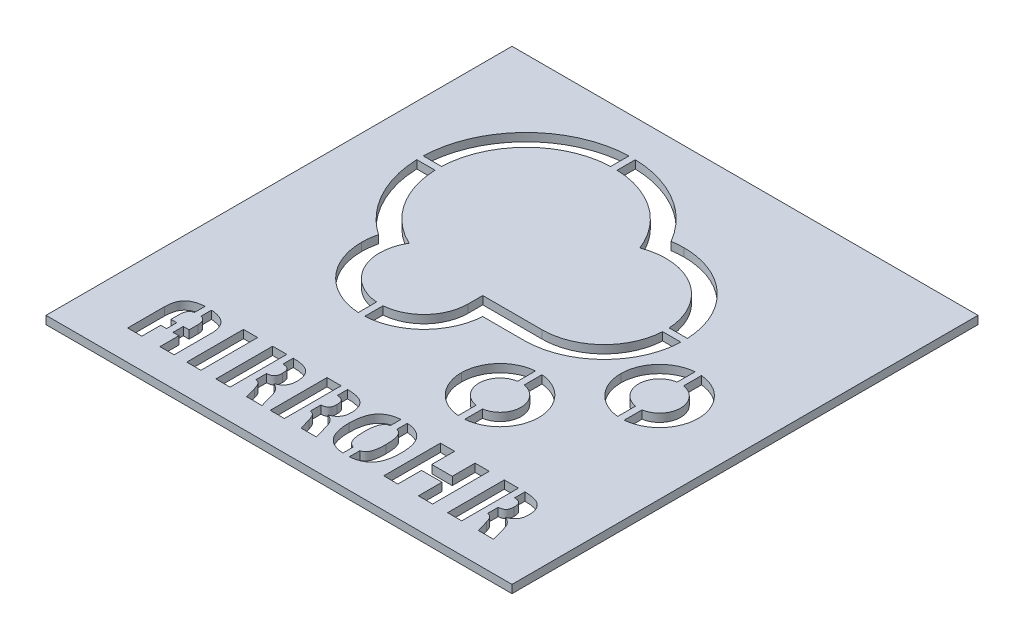
from build123d import *

# Parameters (mm, degrees)
BOSS_EXTRUDE2_DEPTH   = 2
SKETCH4_W             = 115
SKETCH4_H             = 115
BOSS_EXTRUDE2_2_DEPTH = 2
BOSS_EXTRUDE2_3_DEPTH = 2
BOSS_EXTRUDE2_4_DEPTH = 2
SKETCH5_W             = 3.5
SKETCH5_H             = 14
CUT_EXTRUDE1_DEPTH    = 2
SKETCH6_W             = 1.6
SKETCH6_H             = 9.016392518
SKETCH6_W_2           = 12.548523478
SKETCH6_H_2           = 1.6
SKETCH6_W_3           = 7.900848197
SKETCH6_H_3           = 10.834577131
SKETCH6_H_4           = 23.73823121
SKETCH6_H_5           = 23.744170643
BOSS_EXTRUDE3_DEPTH   = 2
SKETCH7_W             = 1.6
SKETCH7_H             = 20.194444444
BOSS_EXTRUDE4_DEPTH   = 2


with BuildPart() as part:
    # Sketch4 → Boss-Extrude2 (new body)
    with BuildSketch(Plane(origin=(0, 0, 0), x_dir=(1, 0, 0), z_dir=(0, 1, 0))):
        with BuildLine():
            Line((-7.842765972, -9.564784729), (-7.842765972, -13.155399048))
            add(Edge.make_bspline(
                [(-7.842765972, -13.155399048), (-7.842935541, -19.185382566), (-12.733091514, -24.0752597), (-18.763092198, -24.075090131)],
                knots=[6, 6, 6, 6, 7, 7, 7, 7], degree=3))
            add(Edge.make_bspline(
                [(-18.763092198, -24.075090131), (-24.793092882, -24.074920559), (-29.682935683, -19.1847684), (-29.682766111, -13.154784881)],
                knots=[7, 7, 7, 7, 8, 8, 8, 8], degree=3))
            add(Edge.make_bspline(
                [(-29.682766111, -13.154784881), (-29.682766111, -11.079765045), (-29.102785261, -9.139766418), (-28.09776512, -7.489764892)],
                knots=[8, 8, 8, 8, 9, 9, 9, 9], degree=3))
            add(Edge.make_bspline(
                [(-28.09776512, -7.489764892), (-35.447785528, -4.019767486), (-40.527766378, 3.460212982), (-40.527766378, 12.125213898)],
                knots=[9, 9, 9, 9, 10, 10, 10, 10], degree=3))
            add(Edge.make_bspline(
                [(-40.527766378, 12.125213898), (-40.527766378, 24.100233353), (-30.81776634, 33.810213364), (-18.837766798, 33.810213364)],
                knots=[10, 10, 10, 10, 11, 11, 11, 11], degree=3))
            add(Edge.make_bspline(
                [(-18.837766798, 33.810213364), (-9.632766874, 33.810213364), (-1.767746122, 28.070232666), (1.377235262, 19.980232514)],
                knots=[0, 0, 0, 0, 1, 1, 1, 1], degree=3))
            add(Edge.make_bspline(
                [(1.377235262, 19.980232514), (3.067233889, 20.625213898), (4.902232973, 20.980232514), (6.822234957, 20.980232514)],
                knots=[1, 1, 1, 1, 2, 2, 2, 2], degree=3))
            add(Edge.make_bspline(
                [(6.822234957, 20.980232514), (15.257232515, 20.980232514), (22.0922316, 14.145214356), (22.0922316, 5.710212982)],
                knots=[2, 2, 2, 2, 3, 3, 3, 3], degree=3))
            add(Edge.make_bspline(
                [(22.0922316, 5.710212982), (22.0922316, -2.724784576), (15.257232515, -9.564784729), (6.822234957, -9.564784729)],
                knots=[3, 3, 3, 3, 4, 4, 4, 4], degree=3))
            Line((6.822234957, -9.564784729), (-7.842765972, -9.564784729))
        make_face()
    extrude(amount=BOSS_EXTRUDE2_DEPTH)



with BuildPart() as body_2:
    # Sketch4 → Boss-Extrude2 2 (new body)
    with BuildSketch(Plane(origin=(0, 0, 0), x_dir=(1, 0, 0), z_dir=(0, 1, 0))):
        with Locations((0, -10.190399849)):
            Rectangle(SKETCH4_W, SKETCH4_H)
        with BuildLine():
            Line((-3.369278118, -14.064975464), (6.822040394, -14.06540271))
            add(Edge.make_bspline(
                [(6.822040394, -14.06540271), (17.723441914, -14.06540271), (26.592231587, -5.194381439), (26.592231587, 5.709598816)],
                knots=[6, 6, 6, 6, 7, 7, 7, 7], degree=3))
            add(Edge.make_bspline(
                [(26.592231587, 5.709598816), (26.592231587, 16.610832489), (17.723441914, 25.479618347), (6.822234944, 25.479618347)],
                knots=[7, 7, 7, 7, 8, 8, 8, 8], degree=3))
            add(Edge.make_bspline(
                [(6.822234944, 25.479618347), (5.811405018, 25.479618347), (4.809924916, 25.403877533), (3.82228835, 25.253231323)],
                knots=[8, 8, 8, 8, 9, 9, 9, 9], degree=3))
            add(Edge.make_bspline(
                [(3.82228835, 25.253231323), (1.910270527, 28.555517471), (-0.706497356, 31.405149735), (-3.884784862, 33.620214737)],
                knots=[9, 9, 9, 9, 10, 10, 10, 10], degree=3))
            add(Edge.make_bspline(
                [(-3.884784862, 33.620214737), (-8.286651775, 36.688041962), (-13.457325145, 38.309600151), (-18.837766811, 38.309600151)],
                knots=[10, 10, 10, 10, 11, 11, 11, 11], degree=3))
            add(Edge.make_bspline(
                [(-18.837766811, 38.309600151), (-33.278976604, 38.309600151), (-45.027765915, 26.563061035), (-45.027765915, 12.124599732)],
                knots=[0, 0, 0, 0, 1, 1, 1, 1], degree=3))
            add(Edge.make_bspline(
                [(-45.027765915, 12.124599732), (-45.027765915, 3.483356751), (-40.700526401, -4.580489838), (-33.724340602, -9.419315063)],
                knots=[1, 1, 1, 1, 2, 2, 2, 2], degree=3))
            add(Edge.make_bspline(
                [(-33.724340602, -9.419315063), (-34.027487918, -10.634566986), (-34.182766124, -11.888732635), (-34.182766124, -13.155399048)],
                knots=[2, 2, 2, 2, 3, 3, 3, 3], degree=3))
            add(Edge.make_bspline(
                [(-34.182766124, -13.155399048), (-34.182766124, -21.65801593), (-27.265400096, -28.575397217), (-18.762785122, -28.575397217)],
                knots=[3, 3, 3, 3, 4, 4, 4, 4], degree=3))
            add(Edge.make_bspline(
                [(-18.762785122, -28.575397217), (-10.565300151, -28.575397217), (-3.841350719, -22.146121704), (-3.369278118, -14.064975464)],
                knots=[4, 4, 4, 4, 5, 5, 5, 5], degree=3))
        make_face(mode=Mode.SUBTRACT)
        with BuildLine():
            add(Edge.make_bspline(
                [(15.583556965, -38.288196289), (20.8599623, -38.288196289), (25.152625874, -33.995532715), (25.152625874, -28.71912738)],
                knots=[2, 2, 2, 2, 3, 3, 3, 3], degree=3))
            add(Edge.make_bspline(
                [(25.152625874, -28.71912738), (25.152625874, -23.442722046), (20.8599623, -19.150058472), (15.583556965, -19.150058472)],
                knots=[3, 3, 3, 3, 4, 4, 4, 4], degree=3))
            add(Edge.make_bspline(
                [(15.583556965, -19.150058472), (10.307151631, -19.150058472), (6.014484242, -23.442722046), (6.014484242, -28.71912738)],
                knots=[0, 0, 0, 0, 1, 1, 1, 1], degree=3))
            add(Edge.make_bspline(
                [(6.014484242, -28.71912738), (6.014484242, -33.995532715), (10.307151631, -38.288196289), (15.583556965, -38.288196289)],
                knots=[1, 1, 1, 1, 2, 2, 2, 2], degree=3))
        make_face(mode=Mode.SUBTRACT)
        with BuildLine():
            add(Edge.make_bspline(
                [(25.878173664, -9.214587891), (25.878173664, -14.490993225), (30.170837239, -18.783656799), (35.447242573, -18.783656799)],
                knots=[1, 1, 1, 1, 2, 2, 2, 2], degree=3))
            add(Edge.make_bspline(
                [(35.447242573, -18.783656799), (40.723647908, -18.783656799), (45.016311482, -14.490993225), (45.016311482, -9.214587891)],
                knots=[2, 2, 2, 2, 3, 3, 3, 3], degree=3))
            add(Edge.make_bspline(
                [(45.016311482, -9.214587891), (45.016311482, -3.938182556), (40.723647908, 0.354484833), (35.447242573, 0.354484833)],
                knots=[3, 3, 3, 3, 4, 4, 4, 4], degree=3))
            add(Edge.make_bspline(
                [(35.447242573, 0.354484833), (30.170837239, 0.354484833), (25.878173664, -3.938182556), (25.878173664, -9.214587891)],
                knots=[0, 0, 0, 0, 1, 1, 1, 1], degree=3))
        make_face(mode=Mode.SUBTRACT)
    extrude(amount=BOSS_EXTRUDE2_2_DEPTH)

    # Sketch5 → Cut-Extrude1 (cut)
    with BuildSketch(Plane(origin=(0, 2, 0), x_dir=(1, 0, 0), z_dir=(0, 1, 0))):
        with BuildLine():
            Line((-41.222222222, -60.324270548), (-44.722222222, -60.324270548))
            Line((-44.722222222, -60.324270548), (-44.722222222, -51.267412909))
            add(Edge.make_bspline(
                [(-44.722222222, -51.267412909), (-44.718630096, -51.075892532), (-44.711603403, -50.70125237), (-44.659502845, -50.154032457), (-44.573962658, -49.634407069), (-44.459047775, -49.141700933), (-44.298206685, -48.678929554), (-44.089121514, -48.250981461), (-43.826820441, -47.861085276), (-43.518137808, -47.505226321), (-43.156485853, -47.187487984), (-42.741812509, -46.909169818), (-42.272971127, -46.672327608), (-41.748321644, -46.474965295), (-41.162877239, -46.315865875), (-40.510620907, -46.20709583), (-39.791637792, -46.13992868), (-39.29009159, -46.133287839), (-39.028645833, -46.129826104)],
                knots=[0, 0, 0, 0, 0.000574508, 0.001123817, 0.001647269, 0.002153518, 0.002639724, 0.003113926, 0.003578223, 0.004045522, 0.004523399, 0.005018037, 0.005539802, 0.006095601, 0.006697017, 0.007356837, 0.00807696, 0.008861103, 0.008861103, 0.008861103, 0.008861103], degree=3))
            add(Edge.make_bspline(
                [(-39.028645833, -46.129826104), (-38.766193514, -46.133319316), (-38.262637675, -46.140021589), (-37.541549788, -46.206713305), (-36.886521498, -46.316690693), (-36.296927983, -46.474962778), (-35.766199268, -46.67231066), (-35.291531054, -46.909322701), (-34.870759525, -47.186368182), (-34.505957291, -47.506173563), (-34.190881765, -47.860627047), (-33.923166042, -48.251434416), (-33.704355092, -48.678309085), (-33.534343881, -49.141237367), (-33.410700461, -49.63410981), (-33.314159013, -50.153291305), (-33.260253638, -50.701161959), (-33.253467993, -51.075895101), (-33.25, -51.267412909)],
                knots=[0, 0, 0, 0, 0.00078718, 0.001510327, 0.002170147, 0.002777429, 0.003338912, 0.003866098, 0.004365786, 0.004845946, 0.005317258, 0.005784962, 0.006263263, 0.006752563, 0.007261023, 0.007786033, 0.008335636, 0.008910144, 0.008910144, 0.008910144, 0.008910144], degree=3))
            Line((-33.25, -51.267412909), (-33.25, -60.324270548))
            Line((-33.25, -60.324270548), (-36.75, -60.324270548))
            Line((-36.75, -60.324270548), (-36.75, -55.657603882))
            Line((-36.75, -55.657603882), (-41.222222222, -55.657603882))
            Line((-41.222222222, -55.657603882), (-41.222222222, -60.324270548))
        make_face()
        with BuildLine():
            Line((-36.75, -53.129826104), (-36.75, -50.975746243))
            add(Edge.make_bspline(
                [(-36.75, -50.975746243), (-36.751933258, -50.883543096), (-36.755679301, -50.704882493), (-36.779325002, -50.444710356), (-36.822248778, -50.202188177), (-36.878587301, -49.97579093), (-36.955280652, -49.767138409), (-37.049224073, -49.575813978), (-37.158991279, -49.401490084), (-37.284103764, -49.244142011), (-37.429713006, -49.106030456), (-37.593404479, -48.982661933), (-37.781122939, -48.885389065), (-37.982680392, -48.79690934), (-38.206943614, -48.735026033), (-38.449885716, -48.690036828), (-38.712045217, -48.662421305), (-38.892872016, -48.659242802), (-38.986111111, -48.657603882)],
                knots=[0, 0, 0, 0, 0.000276626, 0.000536014, 0.000782763, 0.001014882, 0.001234999, 0.001448323, 0.001653147, 0.001851958, 0.002049651, 0.002253821, 0.002464532, 0.002682352, 0.002913135, 0.003160426, 0.003423138, 0.0037028, 0.0037028, 0.0037028, 0.0037028], degree=3))
            add(Edge.make_bspline(
                [(-38.986111111, -48.657603882), (-39.079350206, -48.659242802), (-39.260177005, -48.662421305), (-39.522336506, -48.690036828), (-39.765278608, -48.735026033), (-39.989541831, -48.79690934), (-40.191099283, -48.885389065), (-40.378817743, -48.982661933), (-40.542509216, -49.106030456), (-40.688118458, -49.244142011), (-40.813230943, -49.401490084), (-40.92299815, -49.575813978), (-41.01694157, -49.767138409), (-41.093634921, -49.97579093), (-41.149973444, -50.202188177), (-41.192897221, -50.444710356), (-41.216542921, -50.704882493), (-41.220288965, -50.883543096), (-41.222222222, -50.975746243)],
                knots=[0, 0, 0, 0, 0.000279662, 0.000542374, 0.000789665, 0.001020448, 0.001238268, 0.001448979, 0.001653149, 0.001850842, 0.002049653, 0.002254477, 0.002467801, 0.002687918, 0.002920037, 0.003166786, 0.003426174, 0.0037028, 0.0037028, 0.0037028, 0.0037028], degree=3))
            Line((-41.222222222, -50.975746243), (-41.222222222, -53.129826104))
            Line((-41.222222222, -53.129826104), (-36.75, -53.129826104))
        make_face(mode=Mode.SUBTRACT)
        with Locations((-28.388888889, -53.324270548)):
            Rectangle(SKETCH5_W, SKETCH5_H)
        with BuildLine():
            add(Edge.make_bspline(
                [(-18.144097222, -46.324270548), (-17.914161938, -46.327621932), (-17.468123346, -46.334123094), (-16.821971374, -46.371585948), (-16.220556147, -46.441684265), (-15.663311684, -46.538131651), (-15.146381878, -46.660942423), (-14.677005595, -46.833108754), (-14.249236029, -47.03798271), (-13.869484241, -47.290174742), (-13.531179835, -47.58081433), (-13.237571737, -47.913339551), (-12.991575073, -48.290574728), (-12.791807589, -48.710011632), (-12.631260833, -49.175207977), (-12.52233888, -49.690434341), (-12.454537253, -50.255901969), (-12.447898826, -50.649437677), (-12.444444444, -50.854218465)],
                knots=[0, 0, 0, 0, 0.000689837, 0.001338177, 0.001940767, 0.002505193, 0.003034266, 0.003532122, 0.004002258, 0.004453918, 0.004895502, 0.005336794, 0.005780037, 0.006242053, 0.006727261, 0.007252878, 0.007818904, 0.008432988, 0.008432988, 0.008432988, 0.008432988], degree=3))
            add(Edge.make_bspline(
                [(-12.444444444, -50.854218465), (-12.44632048, -50.981943127), (-12.449948385, -51.228939036), (-12.490399929, -51.583468023), (-12.552472309, -51.909536672), (-12.644193796, -52.205271029), (-12.758521575, -52.474215962), (-12.886308552, -52.722809597), (-13.030924162, -52.950378557), (-13.244964039, -53.21868066), (-13.540644328, -53.511428788), (-13.938660281, -53.787969721), (-14.351819233, -54.008615948), (-14.633110412, -54.130234846), (-14.771701389, -54.190155965)],
                knots=[0, 0, 0, 0, 0.000383005, 0.000740662, 0.001068969, 0.001377447, 0.001667479, 0.001944689, 0.002215224, 0.002474772, 0.002973203, 0.003457068, 0.003923349, 0.004376203, 0.004376203, 0.004376203, 0.004376203], degree=3))
            add(Edge.make_bspline(
                [(-14.771701389, -54.190155965), (-14.642823998, -54.245218696), (-14.389914439, -54.353274042), (-14.037611931, -54.558592868), (-13.721590982, -54.797263388), (-13.429375266, -55.065997046), (-13.169755896, -55.389150161), (-12.941169155, -55.77768305), (-12.744923213, -56.237063719), (-12.643621617, -56.57196297), (-12.590277778, -56.748315687)],
                knots=[0, 0, 0, 0, 0.000420162, 0.000824527, 0.001219492, 0.001606406, 0.002012571, 0.002458068, 0.002954745, 0.003507204, 0.003507204, 0.003507204, 0.003507204], degree=3))
            Line((-12.590277778, -56.748315687), (-11.560329861, -60.324270548))
            Line((-11.560329861, -60.324270548), (-15.327690972, -60.324270548))
            Line((-15.327690972, -60.324270548), (-16.138888889, -57.556475409))
            add(Edge.make_bspline(
                [(-16.138888889, -57.556475409), (-16.189175659, -57.389603296), (-16.284077937, -57.07467864), (-16.430208893, -56.702253486), (-16.554398353, -56.436443287), (-16.655075347, -56.260254093), (-16.774065288, -56.107392268), (-16.938385992, -55.923161051), (-17.18904089, -55.732089812), (-17.483907531, -55.60208951), (-17.747458575, -55.533140016), (-17.968061139, -55.48742775), (-18.210678935, -55.470133723), (-18.379051456, -55.465537127), (-18.466145833, -55.463159437)],
                knots=[0, 0, 0, 0, 0.000522711, 0.000986471, 0.001198471, 0.001402731, 0.001593534, 0.00177849, 0.00214249, 0.002528712, 0.002736556, 0.002959403, 0.003203387, 0.003464831, 0.003464831, 0.003464831, 0.003464831], degree=3))
            add(Edge.make_bspline(
                [(-18.466145833, -55.463159437), (-18.549189815, -55.463159437), (-18.720341435, -55.463159437), (-18.975549769, -55.463159437), (-19.218605324, -55.463159437), (-19.373553241, -55.463159437), (-19.444444444, -55.463159437)],
                knots=[0, 0, 0, 0, 0.000249132, 0.000513455, 0.000765625, 0.000978299, 0.000978299, 0.000978299, 0.000978299], degree=3))
            Line((-19.444444444, -55.463159437), (-19.444444444, -60.324270548))
            Line((-19.444444444, -60.324270548), (-22.944444444, -60.324270548))
            Line((-22.944444444, -60.324270548), (-22.944444444, -46.324270548))
            Line((-22.944444444, -46.324270548), (-18.144097222, -46.324270548))
        make_face()
        with BuildLine():
            add(Edge.make_bspline(
                [(-19.444444444, -52.874617771), (-19.341248676, -52.886864369), (-19.133266311, -52.911546355), (-18.821803568, -52.928215224), (-18.521861585, -52.932389432), (-18.327402149, -52.934419541), (-18.235243056, -52.935381659)],
                knots=[0, 0, 0, 0, 0.000311693, 0.00062819, 0.000935108, 0.0012116, 0.0012116, 0.0012116, 0.0012116], degree=3))
            add(Edge.make_bspline(
                [(-18.235243056, -52.935381659), (-18.137933608, -52.934988452), (-17.949056726, -52.934225239), (-17.677758503, -52.906485456), (-17.425084051, -52.876889917), (-17.196144051, -52.82379088), (-16.98525581, -52.761781288), (-16.799392867, -52.678886989), (-16.630135867, -52.587895833), (-16.48283296, -52.47719635), (-16.354229165, -52.348233086), (-16.241527622, -52.200050725), (-16.153859223, -52.02738246), (-16.070691118, -51.838541476), (-16.017231926, -51.624615592), (-15.973064329, -51.392541002), (-15.950155849, -51.139240773), (-15.946396406, -50.963628356), (-15.944444444, -50.872447632)],
                knots=[0, 0, 0, 0, 0.00029173, 0.000566246, 0.000817609, 0.001054218, 0.001270443, 0.001475897, 0.001663578, 0.00184587, 0.002026329, 0.002208621, 0.002401636, 0.002605897, 0.002826265, 0.003061053, 0.003314392, 0.003587981, 0.003587981, 0.003587981, 0.003587981], degree=3))
            add(Edge.make_bspline(
                [(-15.944444444, -50.872447632), (-15.946323512, -50.774167334), (-15.949913514, -50.58640064), (-15.973328703, -50.317099572), (-16.015141713, -50.075192306), (-16.072805036, -49.858031443), (-16.147913821, -49.665546049), (-16.242522434, -49.496474514), (-16.355634766, -49.350012307), (-16.492822509, -49.230770407), (-16.646275415, -49.130998432), (-16.814544676, -49.044321721), (-17.000677798, -48.978188291), (-17.281137183, -48.912613128), (-17.679601745, -48.86291617), (-18.011270644, -48.85584942), (-18.189670139, -48.852048326)],
                knots=[0, 0, 0, 0, 0.000294846, 0.000563309, 0.000810059, 0.001030427, 0.001236353, 0.001428169, 0.001609903, 0.001788537, 0.00197055, 0.002158059, 0.002355073, 0.002561402, 0.003021165, 0.00355631, 0.00355631, 0.00355631, 0.00355631], degree=3))
            Line((-18.189670139, -48.852048326), (-19.444444444, -48.852048326))
            Line((-19.444444444, -48.852048326), (-19.444444444, -52.874617771))
        make_face(mode=Mode.SUBTRACT)
        with BuildLine():
            add(Edge.make_bspline(
                [(-4.727430556, -46.324270548), (-4.497495271, -46.327621932), (-4.051456679, -46.334123094), (-3.405304708, -46.371585948), (-2.803889481, -46.441684265), (-2.246645017, -46.538131651), (-1.729715211, -46.660942423), (-1.260338929, -46.833108754), (-0.832569363, -47.03798271), (-0.452817574, -47.290174742), (-0.114513169, -47.58081433), (0.179094929, -47.913339551), (0.425091594, -48.290574728), (0.624859078, -48.710011632), (0.785405833, -49.175207977), (0.894327787, -49.690434341), (0.962129414, -50.255901969), (0.968767841, -50.649437677), (0.972222222, -50.854218465)],
                knots=[0, 0, 0, 0, 0.000689837, 0.001338177, 0.001940767, 0.002505193, 0.003034266, 0.003532122, 0.004002258, 0.004453918, 0.004895502, 0.005336794, 0.005780037, 0.006242053, 0.006727261, 0.007252878, 0.007818904, 0.008432988, 0.008432988, 0.008432988, 0.008432988], degree=3))
            add(Edge.make_bspline(
                [(0.972222222, -50.854218465), (0.970346187, -50.981943127), (0.966718281, -51.228939036), (0.926266738, -51.583468023), (0.864194357, -51.909536672), (0.772472871, -52.205271029), (0.658145092, -52.474215962), (0.530358115, -52.722809597), (0.385742505, -52.950378557), (0.171702627, -53.21868066), (-0.123977661, -53.511428788), (-0.521993614, -53.787969721), (-0.935152567, -54.008615948), (-1.216443745, -54.130234846), (-1.355034722, -54.190155965)],
                knots=[0, 0, 0, 0, 0.000383005, 0.000740662, 0.001068969, 0.001377447, 0.001667479, 0.001944689, 0.002215224, 0.002474772, 0.002973203, 0.003457068, 0.003923349, 0.004376203, 0.004376203, 0.004376203, 0.004376203], degree=3))
            add(Edge.make_bspline(
                [(-1.355034722, -54.190155965), (-1.226157331, -54.245218696), (-0.973247772, -54.353274042), (-0.620945264, -54.558592868), (-0.304924315, -54.797263388), (-0.012708599, -55.065997046), (0.24691077, -55.389150161), (0.475497511, -55.77768305), (0.671743454, -56.237063719), (0.77304505, -56.57196297), (0.826388889, -56.748315687)],
                knots=[0, 0, 0, 0, 0.000420162, 0.000824527, 0.001219492, 0.001606406, 0.002012571, 0.002458068, 0.002954745, 0.003507204, 0.003507204, 0.003507204, 0.003507204], degree=3))
            Line((0.826388889, -56.748315687), (1.856336806, -60.324270548))
            Line((1.856336806, -60.324270548), (-1.911024306, -60.324270548))
            Line((-1.911024306, -60.324270548), (-2.722222222, -57.556475409))
            add(Edge.make_bspline(
                [(-2.722222222, -57.556475409), (-2.772508992, -57.389603296), (-2.86741127, -57.07467864), (-3.013542226, -56.702253486), (-3.137731686, -56.436443287), (-3.23840868, -56.260254093), (-3.357398621, -56.107392268), (-3.521719325, -55.923161051), (-3.772374223, -55.732089812), (-4.067240864, -55.60208951), (-4.330791908, -55.533140016), (-4.551394472, -55.48742775), (-4.794012269, -55.470133723), (-4.962384789, -55.465537127), (-5.049479167, -55.463159437)],
                knots=[0, 0, 0, 0, 0.000522711, 0.000986471, 0.001198471, 0.001402731, 0.001593534, 0.00177849, 0.00214249, 0.002528712, 0.002736556, 0.002959403, 0.003203387, 0.003464831, 0.003464831, 0.003464831, 0.003464831], degree=3))
            add(Edge.make_bspline(
                [(-5.049479167, -55.463159437), (-5.132523148, -55.463159437), (-5.303674769, -55.463159437), (-5.558883102, -55.463159437), (-5.801938657, -55.463159437), (-5.956886574, -55.463159437), (-6.027777778, -55.463159437)],
                knots=[0, 0, 0, 0, 0.000249132, 0.000513455, 0.000765625, 0.000978299, 0.000978299, 0.000978299, 0.000978299], degree=3))
            Line((-6.027777778, -55.463159437), (-6.027777778, -60.324270548))
            Line((-6.027777778, -60.324270548), (-9.527777778, -60.324270548))
            Line((-9.527777778, -60.324270548), (-9.527777778, -46.324270548))
            Line((-9.527777778, -46.324270548), (-4.727430556, -46.324270548))
        make_face()
        with BuildLine():
            add(Edge.make_bspline(
                [(-6.027777778, -52.874617771), (-5.924582009, -52.886864369), (-5.716599645, -52.911546355), (-5.405136902, -52.928215224), (-5.105194919, -52.932389432), (-4.910735483, -52.934419541), (-4.818576389, -52.935381659)],
                knots=[0, 0, 0, 0, 0.000311693, 0.00062819, 0.000935108, 0.0012116, 0.0012116, 0.0012116, 0.0012116], degree=3))
            add(Edge.make_bspline(
                [(-4.818576389, -52.935381659), (-4.721266941, -52.934988452), (-4.532390059, -52.934225239), (-4.261091836, -52.906485456), (-4.008417385, -52.876889917), (-3.779477384, -52.82379088), (-3.568589143, -52.761781288), (-3.3827262, -52.678886989), (-3.2134692, -52.587895833), (-3.066166293, -52.47719635), (-2.937562499, -52.348233086), (-2.824860955, -52.200050725), (-2.737192557, -52.02738246), (-2.654024451, -51.838541476), (-2.600565259, -51.624615592), (-2.556397663, -51.392541002), (-2.533489182, -51.139240773), (-2.52972974, -50.963628356), (-2.527777778, -50.872447632)],
                knots=[0, 0, 0, 0, 0.00029173, 0.000566246, 0.000817609, 0.001054218, 0.001270443, 0.001475897, 0.001663578, 0.00184587, 0.002026329, 0.002208621, 0.002401636, 0.002605897, 0.002826265, 0.003061053, 0.003314392, 0.003587981, 0.003587981, 0.003587981, 0.003587981], degree=3))
            add(Edge.make_bspline(
                [(-2.527777778, -50.872447632), (-2.529656846, -50.774167334), (-2.533246847, -50.58640064), (-2.556662037, -50.317099572), (-2.598475046, -50.075192306), (-2.656138369, -49.858031443), (-2.731247154, -49.665546049), (-2.825855767, -49.496474514), (-2.938968099, -49.350012307), (-3.076155843, -49.230770407), (-3.229608749, -49.130998432), (-3.397878009, -49.044321721), (-3.584011131, -48.978188291), (-3.864470516, -48.912613128), (-4.262935079, -48.86291617), (-4.594603977, -48.85584942), (-4.773003472, -48.852048326)],
                knots=[0, 0, 0, 0, 0.000294846, 0.000563309, 0.000810059, 0.001030427, 0.001236353, 0.001428169, 0.001609903, 0.001788537, 0.00197055, 0.002158059, 0.002355073, 0.002561402, 0.003021165, 0.00355631, 0.00355631, 0.00355631, 0.00355631], degree=3))
            Line((-4.773003472, -48.852048326), (-6.027777778, -48.852048326))
            Line((-6.027777778, -48.852048326), (-6.027777778, -52.874617771))
        make_face(mode=Mode.SUBTRACT)
        with BuildLine():
            add(Edge.make_bspline(
                [(15.75, -53.345537909), (15.745955464, -53.644473341), (15.738126442, -54.223123714), (15.66052951, -55.060466089), (15.538459454, -55.836592885), (15.366990573, -56.552121281), (15.142728851, -57.204621255), (14.869580489, -57.797023858), (14.542880981, -58.326326093), (14.16739736, -58.795953419), (13.738485504, -59.205541918), (13.259074035, -59.558568441), (12.728714174, -59.858481995), (12.147115946, -60.101482098), (11.515383845, -60.289118568), (10.832543417, -60.420694451), (10.100022239, -60.504376078), (9.59384323, -60.513842835), (9.333333333, -60.518714993)],
                knots=[0, 0, 0, 0, 0.000896597, 0.001735546, 0.002520236, 0.003251961, 0.003939909, 0.004586902, 0.005204919, 0.00580135, 0.006385837, 0.006978908, 0.007582989, 0.008209329, 0.008865839, 0.009556419, 0.010293205, 0.011074499, 0.011074499, 0.011074499, 0.011074499], degree=3))
            add(Edge.make_bspline(
                [(9.333333333, -60.518714993), (9.070798574, -60.513872193), (8.561587918, -60.504479131), (7.825015373, -60.42071344), (7.139215689, -60.288998172), (6.505151285, -60.102126379), (5.922908231, -59.858256869), (5.392646578, -59.559587329), (4.915950173, -59.204356938), (4.486942647, -58.79697476), (4.114812816, -58.325998317), (3.790776791, -57.79696428), (3.521487534, -57.203877907), (3.296650547, -56.552185202), (3.124273242, -55.836876279), (3.007267904, -55.060131551), (2.928222217, -54.223172633), (2.920602878, -53.644490005), (2.916666667, -53.345537909)],
                knots=[0, 0, 0, 0, 0.000787367, 0.001527172, 0.002220733, 0.002880154, 0.003506494, 0.004110575, 0.004701205, 0.005285693, 0.005880225, 0.006496649, 0.007142363, 0.007830312, 0.008562037, 0.009346251, 0.010185199, 0.011081796, 0.011081796, 0.011081796, 0.011081796], degree=3))
            add(Edge.make_bspline(
                [(2.916666667, -53.345537909), (2.92055363, -53.042535465), (2.928054902, -52.457784958), (3.007248688, -51.612725192), (3.124441991, -50.83), (3.295990483, -50.109361816), (3.522432312, -49.45325115), (3.789189339, -48.855938287), (4.114781279, -48.32543904), (4.48805957, -47.854821029), (4.91390677, -47.443799252), (5.393750443, -47.092330584), (5.9234497, -46.793795816), (6.504408367, -46.545611648), (7.139320511, -46.359806966), (7.824984759, -46.227750542), (8.561596367, -46.144083247), (9.070801448, -46.134676143), (9.333333333, -46.129826104)],
                knots=[0, 0, 0, 0, 0.000908745, 0.001753746, 0.002543963, 0.003281593, 0.003972414, 0.004623651, 0.005240075, 0.005834607, 0.006421199, 0.007010021, 0.007614103, 0.008241628, 0.008901049, 0.00959461, 0.010334415, 0.011121782, 0.011121782, 0.011121782, 0.011121782], degree=3))
            add(Edge.make_bspline(
                [(9.333333333, -46.129826104), (9.595865219, -46.134676143), (10.1050703, -46.144083247), (10.841681907, -46.227750542), (11.527346156, -46.359806966), (12.162258299, -46.545611648), (12.743216967, -46.793795816), (13.272916224, -47.092330584), (13.752759896, -47.443799252), (14.178607096, -47.854821029), (14.551885388, -48.32543904), (14.877477328, -48.855938287), (15.144234354, -49.45325115), (15.370676184, -50.109361816), (15.542224676, -50.83), (15.659417978, -51.612725192), (15.738611764, -52.457784958), (15.746113037, -53.042535465), (15.75, -53.345537909)],
                knots=[0, 0, 0, 0, 0.000787367, 0.001527172, 0.002220733, 0.002880154, 0.003507679, 0.004111761, 0.004700583, 0.005287175, 0.005881707, 0.006498131, 0.007149368, 0.007840189, 0.008577819, 0.009368036, 0.010213037, 0.011121782, 0.011121782, 0.011121782, 0.011121782], degree=3))
        make_face()
        with BuildLine():
            add(Edge.make_bspline(
                [(12.055555556, -53.324270548), (12.054174674, -53.114595213), (12.051518034, -52.711206693), (12.021267423, -52.132393436), (11.971244008, -51.604950136), (11.898176939, -51.129379091), (11.808259578, -50.699351052), (11.695745265, -50.313794529), (11.55391254, -49.972766094), (11.394673357, -49.672558967), (11.210565095, -49.415279034), (11.008961519, -49.194624678), (10.783062419, -49.017133666), (10.534539284, -48.881560122), (10.267598265, -48.782800271), (9.981887333, -48.708190416), (9.674820126, -48.666795409), (9.463079362, -48.660717636), (9.354600694, -48.657603882)],
                knots=[0, 0, 0, 0, 0.000628972, 0.001210062, 0.001738201, 0.002217736, 0.002652739, 0.003055492, 0.003420543, 0.00375904, 0.004072666, 0.004367183, 0.004652838, 0.00493023, 0.005212929, 0.005504738, 0.00581453, 0.006139971, 0.006139971, 0.006139971, 0.006139971], degree=3))
            add(Edge.make_bspline(
                [(9.354600694, -48.657603882), (9.243075936, -48.660650679), (9.026271922, -48.66657365), (8.711305821, -48.708670907), (8.418243867, -48.782209425), (8.144552662, -48.881697255), (7.890287757, -49.016114804), (7.660876845, -49.194580489), (7.456226311, -49.415152245), (7.268810367, -49.671702014), (7.109267333, -49.972202915), (6.971533479, -50.31450154), (6.85924448, -50.699684719), (6.763453573, -51.128650778), (6.696961156, -51.605351899), (6.64492114, -52.132315992), (6.615284845, -52.711228757), (6.612538579, -53.114602759), (6.611111111, -53.324270548)],
                knots=[0, 0, 0, 0, 0.000334546, 0.000650358, 0.000951001, 0.00123939, 0.001522121, 0.001810174, 0.002106767, 0.002422169, 0.002760666, 0.003124565, 0.003527318, 0.003962967, 0.004442049, 0.004970189, 0.005551279, 0.006180251, 0.006180251, 0.006180251, 0.006180251], degree=3))
            add(Edge.make_bspline(
                [(6.611111111, -53.324270548), (6.612538186, -53.53393849), (6.615283695, -53.937312787), (6.644925175, -54.516223535), (6.696948049, -55.043194297), (6.763495941, -55.519873834), (6.85910627, -55.948910151), (6.972253007, -56.334764598), (7.108519644, -56.678649472), (7.268827263, -56.979930214), (7.456412678, -57.236150802), (7.659754697, -57.45752093), (7.892191168, -57.631535913), (8.143560003, -57.770487842), (8.417940152, -57.8700013), (8.711765516, -57.938887697), (9.026211726, -57.982244464), (9.243055489, -57.987984513), (9.354600694, -57.990937215)],
                knots=[0, 0, 0, 0, 0.000628972, 0.001210062, 0.001738201, 0.002217283, 0.002652933, 0.003055686, 0.003422403, 0.003760899, 0.004076301, 0.004372895, 0.004659098, 0.004943279, 0.005231668, 0.005531589, 0.0058474, 0.006181946, 0.006181946, 0.006181946, 0.006181946], degree=3))
            add(Edge.make_bspline(
                [(9.354600694, -57.990937215), (9.463100598, -57.987917574), (9.674882812, -57.982023502), (9.981409983, -57.939361009), (10.267918989, -57.869420635), (10.535539885, -57.770599049), (10.781145476, -57.630549478), (11.010091509, -57.457465312), (11.21037625, -57.23602492), (11.394656661, -56.979072504), (11.554664498, -56.678094685), (11.69501911, -56.335462287), (11.808399504, -55.949245769), (11.898133953, -55.519144887), (11.971257304, -55.043596256), (12.021263331, -54.516146031), (12.0515192, -53.937334868), (12.054175073, -53.533946042), (12.055555556, -53.324270548)],
                knots=[0, 0, 0, 0, 0.000325442, 0.000635233, 0.000926298, 0.001208997, 0.001487866, 0.001771657, 0.002066174, 0.0023798, 0.002718296, 0.003086156, 0.003488909, 0.003923912, 0.004403447, 0.004931586, 0.005512676, 0.006141648, 0.006141648, 0.006141648, 0.006141648], degree=3))
        make_face(mode=Mode.SUBTRACT)
        Polygon((21.972222222, -46.324270548), (21.972222222, -51.963159437), (27.027777778, -51.963159437), (27.027777778, -46.324270548), (30.527777778, -46.324270548), (30.527777778, -60.324270548), (27.027777778, -60.324270548), (27.027777778, -54.490937215), (21.972222222, -54.490937215), (21.972222222, -60.324270548), (18.472222222, -60.324270548), (18.472222222, -46.324270548), align=None)
        with BuildLine():
            add(Edge.make_bspline(
                [(39.022569444, -46.324270548), (39.252504729, -46.327621932), (39.698543321, -46.334123094), (40.344695292, -46.371585948), (40.946110519, -46.441684265), (41.503354983, -46.538131651), (42.020284789, -46.660942423), (42.489661071, -46.833108754), (42.917430637, -47.03798271), (43.297182426, -47.290174742), (43.635486831, -47.58081433), (43.929094929, -47.913339551), (44.175091594, -48.290574728), (44.374859078, -48.710011632), (44.535405833, -49.175207977), (44.644327787, -49.690434341), (44.712129414, -50.255901969), (44.718767841, -50.649437677), (44.722222222, -50.854218465)],
                knots=[0, 0, 0, 0, 0.000689837, 0.001338177, 0.001940767, 0.002505193, 0.003034266, 0.003532122, 0.004002258, 0.004453918, 0.004895502, 0.005336794, 0.005780037, 0.006242053, 0.006727261, 0.007252878, 0.007818904, 0.008432988, 0.008432988, 0.008432988, 0.008432988], degree=3))
            add(Edge.make_bspline(
                [(44.722222222, -50.854218465), (44.720346187, -50.981943127), (44.716718281, -51.228939036), (44.676266738, -51.583468023), (44.614194357, -51.909536672), (44.522472871, -52.205271029), (44.408145092, -52.474215962), (44.280358115, -52.722809597), (44.135742505, -52.950378557), (43.921702627, -53.21868066), (43.626022339, -53.511428788), (43.228006386, -53.787969721), (42.814847433, -54.008615948), (42.533556255, -54.130234846), (42.394965278, -54.190155965)],
                knots=[0, 0, 0, 0, 0.000383005, 0.000740662, 0.001068969, 0.001377447, 0.001667479, 0.001944689, 0.002215224, 0.002474772, 0.002973203, 0.003457068, 0.003923349, 0.004376203, 0.004376203, 0.004376203, 0.004376203], degree=3))
            add(Edge.make_bspline(
                [(42.394965278, -54.190155965), (42.523842669, -54.245218696), (42.776752228, -54.353274042), (43.129054736, -54.558592868), (43.445075685, -54.797263388), (43.737291401, -55.065997046), (43.99691077, -55.389150161), (44.225497511, -55.77768305), (44.421743454, -56.237063719), (44.52304505, -56.57196297), (44.576388889, -56.748315687)],
                knots=[0, 0, 0, 0, 0.000420162, 0.000824527, 0.001219492, 0.001606406, 0.002012571, 0.002458068, 0.002954745, 0.003507204, 0.003507204, 0.003507204, 0.003507204], degree=3))
            Line((44.576388889, -56.748315687), (45.606336806, -60.324270548))
            Line((45.606336806, -60.324270548), (41.838975694, -60.324270548))
            Line((41.838975694, -60.324270548), (41.027777778, -57.556475409))
            add(Edge.make_bspline(
                [(41.027777778, -57.556475409), (40.977491008, -57.389603296), (40.88258873, -57.07467864), (40.736457774, -56.702253486), (40.612268314, -56.436443287), (40.51159132, -56.260254093), (40.392601379, -56.107392268), (40.228280675, -55.923161051), (39.977625777, -55.732089812), (39.682759136, -55.60208951), (39.419208092, -55.533140016), (39.198605528, -55.48742775), (38.955987731, -55.470133723), (38.787615211, -55.465537127), (38.700520833, -55.463159437)],
                knots=[0, 0, 0, 0, 0.000522711, 0.000986471, 0.001198471, 0.001402731, 0.001593534, 0.00177849, 0.00214249, 0.002528712, 0.002736556, 0.002959403, 0.003203387, 0.003464831, 0.003464831, 0.003464831, 0.003464831], degree=3))
            add(Edge.make_bspline(
                [(38.700520833, -55.463159437), (38.617476852, -55.463159437), (38.446325231, -55.463159437), (38.191116898, -55.463159437), (37.948061343, -55.463159437), (37.793113426, -55.463159437), (37.722222222, -55.463159437)],
                knots=[0, 0, 0, 0, 0.000249132, 0.000513455, 0.000765625, 0.000978299, 0.000978299, 0.000978299, 0.000978299], degree=3))
            Line((37.722222222, -55.463159437), (37.722222222, -60.324270548))
            Line((37.722222222, -60.324270548), (34.222222222, -60.324270548))
            Line((34.222222222, -60.324270548), (34.222222222, -46.324270548))
            Line((34.222222222, -46.324270548), (39.022569444, -46.324270548))
        make_face()
        with BuildLine():
            add(Edge.make_bspline(
                [(37.722222222, -52.874617771), (37.825417991, -52.886864369), (38.033400355, -52.911546355), (38.344863098, -52.928215224), (38.644805081, -52.932389432), (38.839264517, -52.934419541), (38.931423611, -52.935381659)],
                knots=[0, 0, 0, 0, 0.000311693, 0.00062819, 0.000935108, 0.0012116, 0.0012116, 0.0012116, 0.0012116], degree=3))
            add(Edge.make_bspline(
                [(38.931423611, -52.935381659), (39.028733059, -52.934988452), (39.217609941, -52.934225239), (39.488908164, -52.906485456), (39.741582615, -52.876889917), (39.970522616, -52.82379088), (40.181410857, -52.761781288), (40.3672738, -52.678886989), (40.5365308, -52.587895833), (40.683833707, -52.47719635), (40.812437501, -52.348233086), (40.925139045, -52.200050725), (41.012807443, -52.02738246), (41.095975549, -51.838541476), (41.149434741, -51.624615592), (41.193602337, -51.392541002), (41.216510818, -51.139240773), (41.22027026, -50.963628356), (41.222222222, -50.872447632)],
                knots=[0, 0, 0, 0, 0.00029173, 0.000566246, 0.000817609, 0.001054218, 0.001270443, 0.001475897, 0.001663578, 0.00184587, 0.002026329, 0.002208621, 0.002401636, 0.002605897, 0.002826265, 0.003061053, 0.003314392, 0.003587981, 0.003587981, 0.003587981, 0.003587981], degree=3))
            add(Edge.make_bspline(
                [(41.222222222, -50.872447632), (41.220343154, -50.774167334), (41.216753153, -50.58640064), (41.193337963, -50.317099572), (41.151524954, -50.075192306), (41.093861631, -49.858031443), (41.018752846, -49.665546049), (40.924144233, -49.496474514), (40.811031901, -49.350012307), (40.673844157, -49.230770407), (40.520391251, -49.130998432), (40.352121991, -49.044321721), (40.165988869, -48.978188291), (39.885529484, -48.912613128), (39.487064921, -48.86291617), (39.155396023, -48.85584942), (38.976996528, -48.852048326)],
                knots=[0, 0, 0, 0, 0.000294846, 0.000563309, 0.000810059, 0.001030427, 0.001236353, 0.001428169, 0.001609903, 0.001788537, 0.00197055, 0.002158059, 0.002355073, 0.002561402, 0.003021165, 0.00355631, 0.00355631, 0.00355631, 0.00355631], degree=3))
            Line((38.976996528, -48.852048326), (37.722222222, -48.852048326))
            Line((37.722222222, -48.852048326), (37.722222222, -52.874617771))
        make_face(mode=Mode.SUBTRACT)
    extrude(amount=-CUT_EXTRUDE1_DEPTH, mode=Mode.SUBTRACT)


with BuildPart() as body_3:
    # Sketch4 → Boss-Extrude2 3 (new body)
    with BuildSketch(Plane(origin=(0, 0, 0), x_dir=(1, 0, 0), z_dir=(0, 1, 0))):
        with BuildLine():
            add(Edge.make_bspline(
                [(15.583556965, -33.903529846), (12.720283345, -33.903529846), (10.399150685, -31.582401001), (10.399150685, -28.71912738), (10.399150685, -25.855869018), (12.720283345, -23.534724914), (15.583556965, -23.534724914)],
                knots=[2, 2, 2, 2, 3, 3, 3, 4, 4, 4, 4], degree=3))
            add(Edge.make_bspline(
                [(15.583556965, -23.534724914), (18.446830586, -23.534724914), (20.767959431, -25.855869018), (20.767959431, -28.71912738), (20.767959431, -31.582401001), (18.446830586, -33.903529846), (15.583556965, -33.903529846)],
                knots=[0, 0, 0, 0, 1, 1, 1, 2, 2, 2, 2], degree=3))
        make_face()
    extrude(amount=BOSS_EXTRUDE2_3_DEPTH)


with BuildPart() as body_4:
    # Sketch4 → Boss-Extrude2 4 (new body)
    with BuildSketch(Plane(origin=(0, 0, 0), x_dir=(1, 0, 0), z_dir=(0, 1, 0))):
        with BuildLine():
            add(Edge.make_bspline(
                [(35.447242573, -14.398990356), (32.583984211, -14.398990356), (30.262840107, -12.077861511), (30.262840107, -9.214587891), (30.262840107, -6.35131427), (32.583984211, -4.03018161), (35.447242573, -4.03018161)],
                knots=[2, 2, 2, 2, 3, 3, 3, 4, 4, 4, 4], degree=3))
            add(Edge.make_bspline(
                [(35.447242573, -4.03018161), (38.310516194, -4.03018161), (40.631645039, -6.35131427), (40.631645039, -9.214587891), (40.631645039, -12.077861511), (38.310516194, -14.398990356), (35.447242573, -14.398990356)],
                knots=[0, 0, 0, 0, 1, 1, 1, 2, 2, 2, 2], degree=3))
        make_face()
    extrude(amount=BOSS_EXTRUDE2_4_DEPTH)


with BuildPart() as part_1:
    add(part.part)

    add(body_2.part)  # Boss-Extrude3 merges body 2

    add(body_3.part)  # Boss-Extrude3 merges body 3

    add(body_4.part)  # Boss-Extrude3 merges body 4
    # Sketch6 → Boss-Extrude3 (add, through all)
    with BuildSketch(Plane(origin=(0, 2, 0), x_dir=(1, 0, 0), z_dir=(0, 1, 0))):
        with Locations((-18.837766811, 35.655126215)):
            Rectangle(SKETCH6_W, SKETCH6_H)
        with Locations((-42.629326227, 12.124599732)):
            Rectangle(SKETCH6_W_2, SKETCH6_H_2)
        with Locations((24.650357956, 5.710212982)):
            Rectangle(SKETCH6_W_3, SKETCH6_H_2)
        with Locations((-18.763092198, -26.41080012)):
            Rectangle(SKETCH6_W, SKETCH6_H_3)
        with Locations((35.447242573, -9.212223903)):
            Rectangle(SKETCH6_W, SKETCH6_H_4)
        with Locations((15.583556965, -28.16625447)):
            Rectangle(SKETCH6_W, SKETCH6_H_5)
    extrude(amount=-BOSS_EXTRUDE3_DEPTH)

    # Sketch7 → Boss-Extrude4 (add)
    with BuildSketch(Plane(origin=(0, 2, 0), x_dir=(1, 0, 0), z_dir=(0, 1, 0))):
        with Locations((-38.986111111, -53.227048326)):
            Rectangle(SKETCH7_W, SKETCH7_H)
        with Locations((-18.644444444, -53.227048326)):
            Rectangle(SKETCH7_W, SKETCH7_H)
        with Locations((-5.227777778, -53.227048326)):
            Rectangle(SKETCH7_W, SKETCH7_H)
        with Locations((9.354600694, -53.227048326)):
            Rectangle(SKETCH7_W, SKETCH7_H)
        with Locations((38.522222222, -53.227048326)):
            Rectangle(SKETCH7_W, SKETCH7_H)
    extrude(amount=-BOSS_EXTRUDE4_DEPTH)


solid = part_1.part
